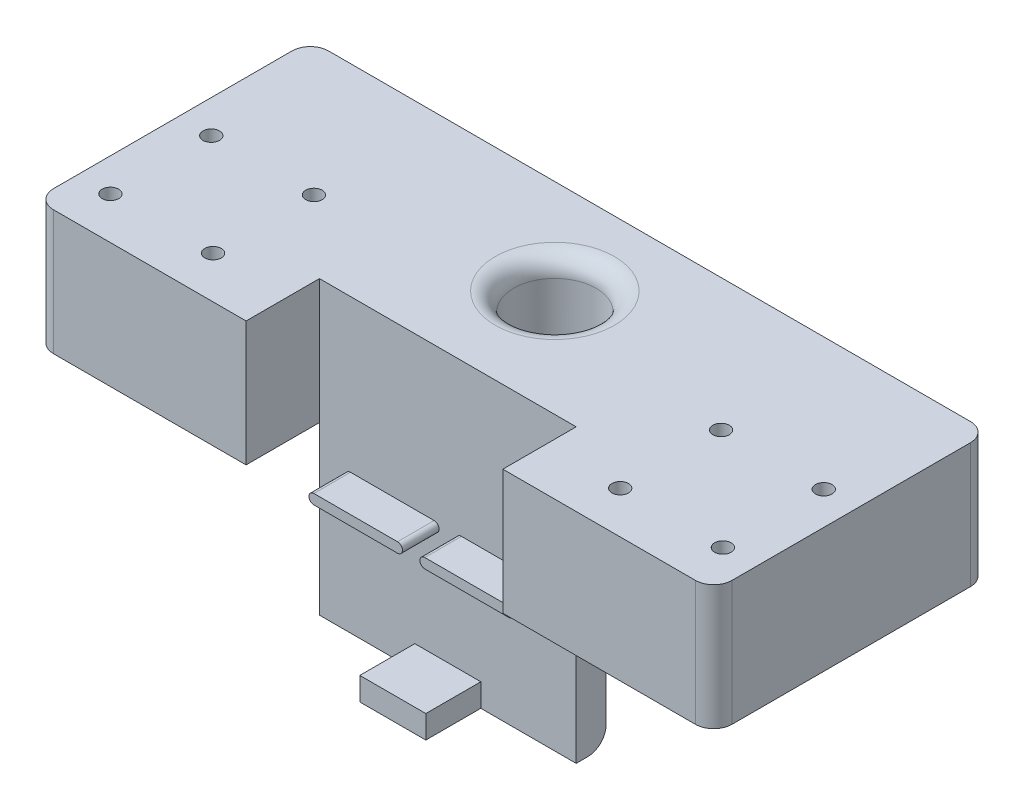
from build123d import *

# Parameters (mm, degrees)
SKETCH1_W                                        = 185
SKETCH1_H                                        = 55
BOSS_EXTRUDE1_DEPTH                              = 49
BOSS_EXTRUDE2_DEPTH                              = 10
SKETCH4_W                                        = 57.5
SKETCH4_H                                        = 15
CUT_EXTRUDE2_DEPTH                               = 66
SKETCH5_W                                        = 57.5
SKETCH5_H                                        = 15
CUT_EXTRUDE3_DEPTH                               = 56
BOSS_EXTRUDE3_DEPTH                              = 10
BOSS_EXTRUDE4_DEPTH                              = 3.5
BOSS_EXTRUDE7_DEPTH                              = 3.5
BOSS_EXTRUDE8_DEPTH                              = 3.5
SKETCH14_W                                       = 70
SKETCH14_H                                       = 4.263818571
CUT_EXTRUDE5_DEPTH                               = 59.5
SKETCH15_W                                       = 57.5
SKETCH15_H                                       = 34
BOSS_EXTRUDE9_DEPTH                              = 20
CBORE_FOR_M4_PAN_HEAD_MACHINE_SCREW1_D           = 4.5
CBORE_FOR_M4_PAN_HEAD_MACHINE_SCREW1_CBORE_D     = 9
CBORE_FOR_M4_PAN_HEAD_MACHINE_SCREW1_CBORE_DEPTH = 3.1
SKETCH19_W                                       = 70
SKETCH19_H                                       = 8.146045787
BOSS_EXTRUDE10_DEPTH                             = 34.74
SKETCH20_W                                       = 18
SKETCH20_H                                       = 6.271934352
BOSS_EXTRUDE11_DEPTH                             = 15
FILLET1_R                                        = 5
SKETCH21_R                                       = 11.25
CUT_EXTRUDE6_DEPTH                               = 80.476181429
FILLET2_R                                        = 5


with BuildPart() as part:
    # Sketch1 → Boss-Extrude1 (new body)
    with BuildSketch(Plane.XZ.offset(15)):
        with Locations((0, 27.5)):
            Rectangle(SKETCH1_W, SKETCH1_H)
    extrude(amount=-BOSS_EXTRUDE1_DEPTH)

    # Sketch2 → Boss-Extrude2 (add)
    with BuildSketch(Plane.XY.offset(55)):
        with BuildLine():
            Line((26.525, -10.2), (3.725, -10.2))
            ThreePointArc((3.725, -10.2), (2.375, -8.85), (3.725, -7.5))
            Line((3.725, -7.5), (26.525, -7.5))
            ThreePointArc((26.525, -7.5), (27.875, -8.85), (26.525, -10.2))
        make_face()
    extrude(amount=BOSS_EXTRUDE2_DEPTH)

    # Sketch4 → Cut-Extrude2 (cut, through all)
    with BuildSketch(Plane(origin=(0, 0, 0), x_dir=(-1, 0, 0), z_dir=(0, 0, -1))):
        with Locations((-63.75, -7.5)):
            Rectangle(SKETCH4_W, SKETCH4_H)
    extrude(amount=-CUT_EXTRUDE2_DEPTH, mode=Mode.SUBTRACT)

    # Sketch5 → Cut-Extrude3 (cut, through all)
    with BuildSketch(Plane.XY.offset(55)):
        with Locations((-63.75, -7.5)):
            Rectangle(SKETCH5_W, SKETCH5_H)
    extrude(amount=-CUT_EXTRUDE3_DEPTH, mode=Mode.SUBTRACT)

    # Sketch6 → Boss-Extrude3 (add)
    with BuildSketch(Plane.XY.offset(55)):
        with BuildLine():
            Line((-26.525, -7.5), (-3.725, -7.5))
            ThreePointArc((-3.725, -7.5), (-2.375, -8.85), (-3.725, -10.2))
            Line((-3.725, -10.2), (-26.525, -10.2))
            ThreePointArc((-26.525, -10.2), (-27.875, -8.85), (-26.525, -7.5))
        make_face()
    extrude(amount=BOSS_EXTRUDE3_DEPTH)

    # Sketch8 → Boss-Extrude4 (add)
    with BuildSketch(Plane(origin=(0, 0, 0), x_dir=(-1, 0, 0), z_dir=(0, 0, -1))):
        with BuildLine():
            Line((-11.45, 16.55), (11.45, 16.55))
            ThreePointArc((11.45, 16.55), (12.75, 15.25), (11.45, 13.95))
            Line((11.45, 13.95), (-11.45, 13.95))
            ThreePointArc((-11.45, 13.95), (-12.75, 15.25), (-11.45, 16.55))
        make_face()
    extrude(amount=BOSS_EXTRUDE4_DEPTH)

    # Sketch11 → Boss-Extrude7 (add)
    with BuildSketch(Plane(origin=(0, 0, 0), x_dir=(-1, 0, 0), z_dir=(0, 0, -1))):
        with BuildLine():
            Line((-31, -3), (31, -3))
            ThreePointArc((31, -3), (33.25, -5.25), (31, -7.5))
            Line((31, -7.5), (-31, -7.5))
            ThreePointArc((-31, -7.5), (-33.25, -5.25), (-31, -3))
        make_face()
    extrude(amount=BOSS_EXTRUDE7_DEPTH)

    # Sketch10 → Boss-Extrude8 (add)
    with BuildSketch(Plane(origin=(0, 0, 0), x_dir=(-1, 0, 0), z_dir=(0, 0, -1))):
        with BuildLine():
            Line((-18.55, 13.95), (-42.45, 13.95))
            ThreePointArc((-42.45, 13.95), (-43.75, 15.25), (-42.45, 16.55))
            Line((-42.45, 16.55), (-18.55, 16.55))
            ThreePointArc((-18.55, 16.55), (-17.25, 15.25), (-18.55, 13.95))
        make_face()
        with BuildLine():
            Line((42.45, 16.55), (18.55, 16.55))
            ThreePointArc((18.55, 16.55), (17.25, 15.25), (18.55, 13.95))
            Line((18.55, 13.95), (42.45, 13.95))
            ThreePointArc((42.45, 13.95), (43.75, 15.25), (42.45, 16.55))
        make_face()
    extrude(amount=BOSS_EXTRUDE8_DEPTH)

    # Sketch14 → Cut-Extrude5 (cut, through all)
    with BuildSketch(Plane.XY.offset(55)):
        with Locations((0, -12.868090715)):
            Rectangle(SKETCH14_W, SKETCH14_H)
    extrude(amount=-CUT_EXTRUDE5_DEPTH, mode=Mode.SUBTRACT)

    # Sketch15 → Boss-Extrude9 (add)
    with BuildSketch(Plane.XY.offset(55)):
        with Locations((-63.75, 17)):
            Rectangle(SKETCH15_W, SKETCH15_H)
        with Locations((63.75, 17)):
            Rectangle(SKETCH15_W, SKETCH15_H)
    extrude(amount=BOSS_EXTRUDE9_DEPTH)

    # CBORE for M4 Pan Head Machine Screw1 (through all)
    with Locations(Plane.XZ):
        with Locations((-55.5, 63.5), (-83.5, 63.5), (-83.5, 36), (-55.5, 36), (55.5, 36), (83.5, 36), (83.5, 63.5), (55.5, 63.5)):
            CounterBoreHole(CBORE_FOR_M4_PAN_HEAD_MACHINE_SCREW1_D / 2, CBORE_FOR_M4_PAN_HEAD_MACHINE_SCREW1_CBORE_D / 2, CBORE_FOR_M4_PAN_HEAD_MACHINE_SCREW1_CBORE_DEPTH)

    # Sketch19 → Boss-Extrude10 (add)
    with BuildSketch(Plane.XZ.offset(10.736181429)):
        with Locations((0, 50.926977107)):
            Rectangle(SKETCH19_W, SKETCH19_H)
    extrude(amount=BOSS_EXTRUDE10_DEPTH)

    # Sketch20 → Boss-Extrude11 (add)
    with BuildSketch(Plane.XY.offset(55)):
        with Locations((0, -42.335967176)):
            Rectangle(SKETCH20_W, SKETCH20_H)
    extrude(amount=BOSS_EXTRUDE11_DEPTH)

    # Fillet1
    fillet1_edges = [part.edges().sort_by_distance(p)[0] for p in [
        (-92.5, 17, 75),
        (92.5, 17, 75),
        (0, -45.476181429, 46.853954213),
        (92.5, 17, 0),
        (-92.5, 17, 0),
    ]]
    fillet(fillet1_edges, radius=FILLET1_R)

    # Sketch21 → Cut-Extrude6 (cut, through all)
    with BuildSketch(Plane(origin=(0, 34, 0), x_dir=(1, 0, 0), z_dir=(0, 1, 0))):
        with Locations((0, -25.818049532)):
            Circle(SKETCH21_R)
    extrude(amount=-CUT_EXTRUDE6_DEPTH, mode=Mode.SUBTRACT)

    # Fillet2
    fillet2_edges = [part.edges().sort_by_distance(p)[0] for p in [
        (-11.25, 34, 25.818049532),
    ]]
    fillet(fillet2_edges, radius=FILLET2_R)


solid = part.part
